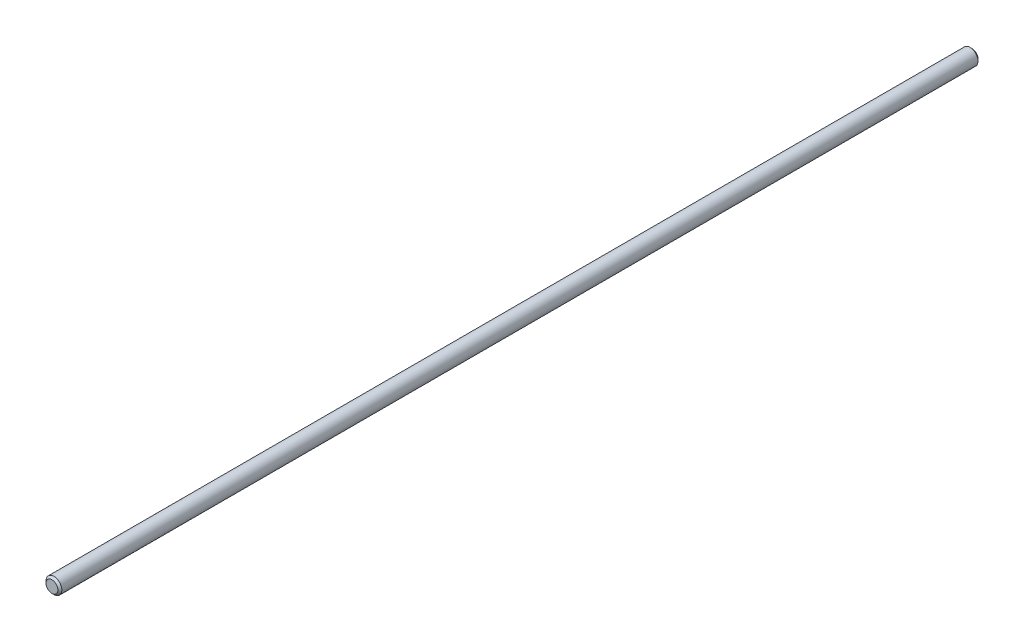
from build123d import *

# Parameters (mm, degrees)
SCHIZZO1_R                   = 4
ESTRUSIONE_ESTRUSIONE1_DEPTH = 465
SMUSSO1_SIZE                 = 1


with BuildPart() as part:
    # Schizzo1 → Estrusione-Estrusione1 (new body)
    with BuildSketch(Plane.XY):
        Circle(SCHIZZO1_R)
    extrude(amount=ESTRUSIONE_ESTRUSIONE1_DEPTH)

    # Smusso1
    smusso1_edges = [part.edges().sort_by_distance(p)[0] for p in [
        (-4, 0, 0),
        (-4, 0, 465),
    ]]
    chamfer(smusso1_edges, length=SMUSSO1_SIZE)


solid = part.part
